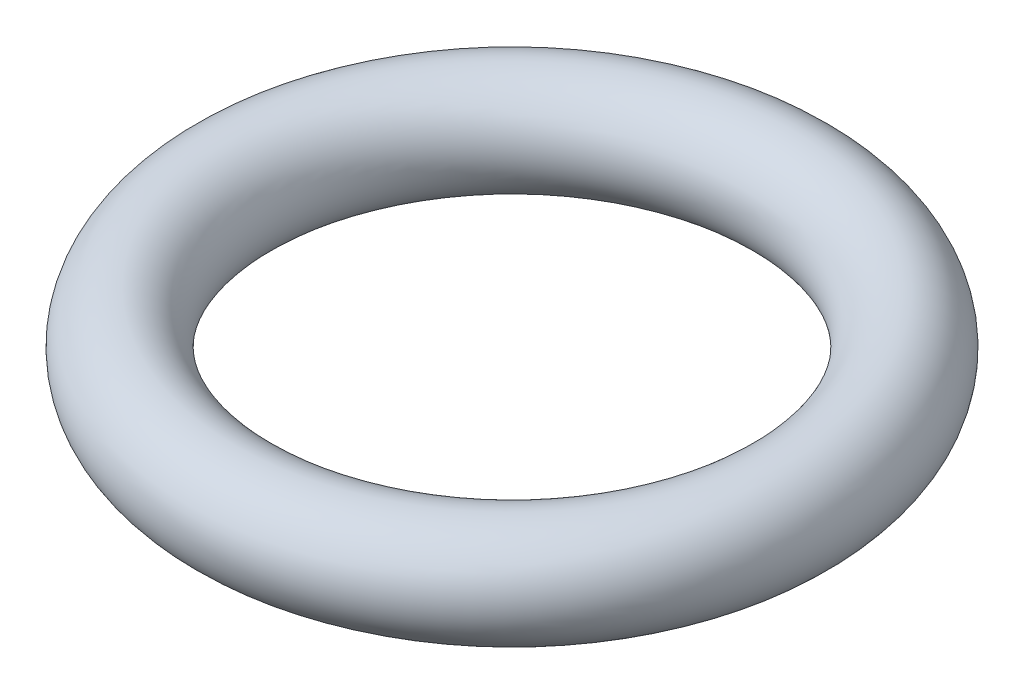
from build123d import *

# Parameters (mm, degrees)
SKETCH3_R = 0.75


with BuildPart() as part:
    # Sketch3 → Revolve1 (revolve)
    with BuildSketch(Plane.XY):
        with Locations((4, 0)):
            Circle(SKETCH3_R)
    revolve(axis=Axis((0, 0, 0), (0, 1, 0)))


solid = part.part
